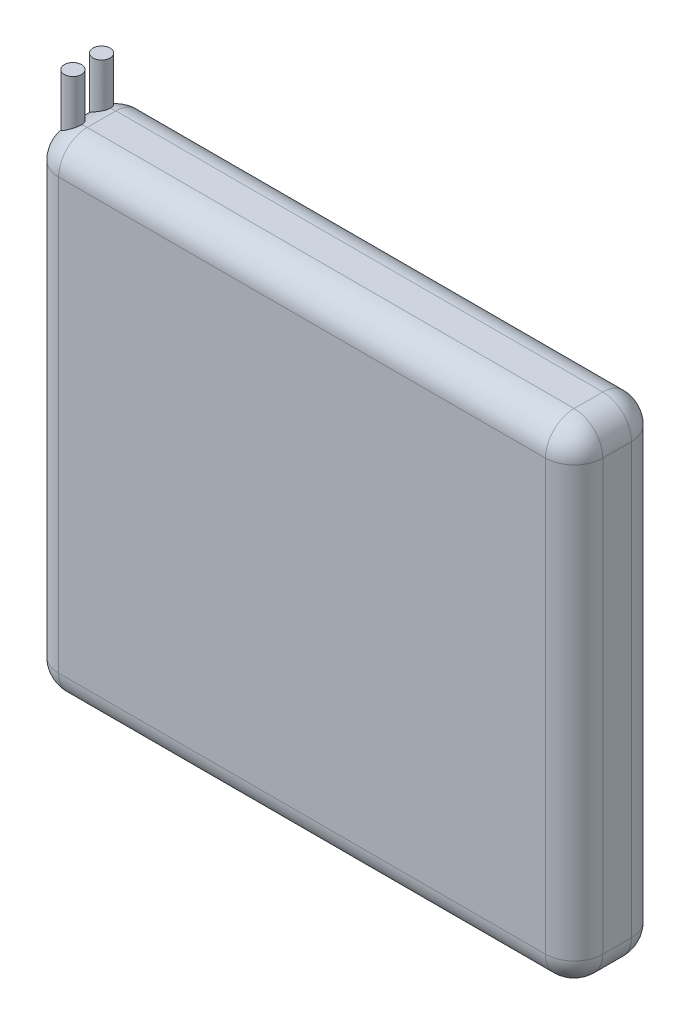
from build123d import *

# Parameters (mm, degrees)
ESQUISSE1_W             = 38
ESQUISSE1_H             = 34
BOSS_EXTRU_1_DEPTH      = 6
CONG_2_R                = 2
ESQUISSE2_R             = 0.6
BOSS_EXTRU_2_DEPTH      = 3
BOSS_EXTRU_2_DEPTH_BACK = 6


with BuildPart() as part:
    # Esquisse1 → Boss.-Extru.1 (new body)
    with BuildSketch(Plane.XY):
        with Locations((19, 17)):
            Rectangle(ESQUISSE1_W, ESQUISSE1_H)
    extrude(amount=BOSS_EXTRU_1_DEPTH)

    # Congé2
    cong_2_edges = [part.edges().sort_by_distance(p)[0] for p in [
        (38, 17, 6),
        (19, 34, 6),
        (0, 17, 6),
        (19, 34, 0),
        (38, 17, 0),
        (19, 0, 0),
        (0, 17, 0),
        (0, 34, 3),
        (38, 34, 3),
        (38, 0, 3),
        (0, 0, 3),
        (19, 0, 6),
    ]]
    fillet(cong_2_edges, radius=CONG_2_R)

    # Esquisse2 → Boss.-Extru.2 (add, two sides)
    with BuildSketch(Plane(origin=(0, 34, 0), x_dir=(1, 0, 0), z_dir=(0, 1, 0))) as boss_extru_2_sk:
        with Locations((1, -2)):
            Circle(ESQUISSE2_R)
        with Locations((1, -4)):
            Circle(ESQUISSE2_R)
    extrude(amount=BOSS_EXTRU_2_DEPTH)
    extrude(boss_extru_2_sk.sketch, amount=-BOSS_EXTRU_2_DEPTH_BACK)


solid = part.part
